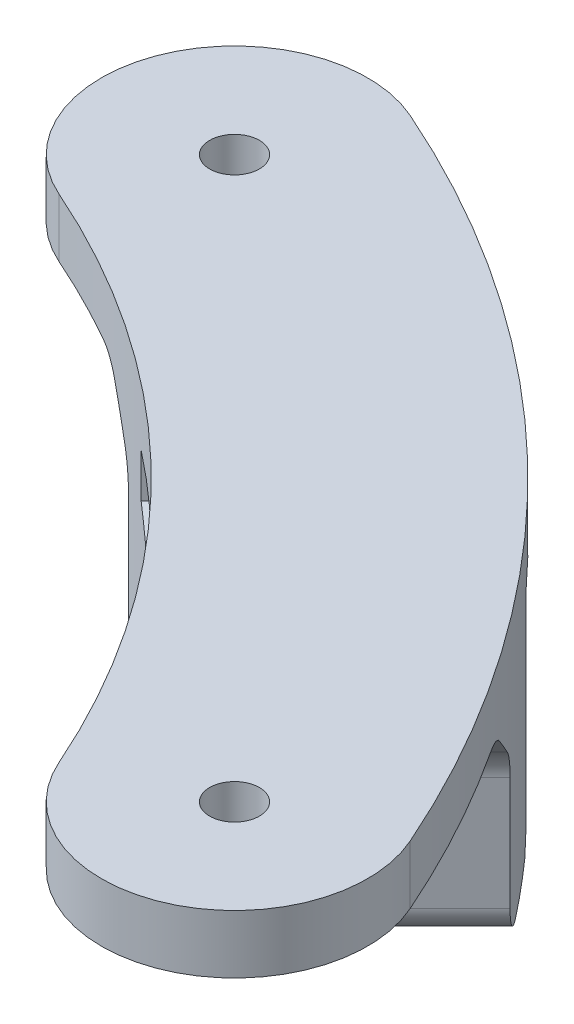
from build123d import *

# Parameters (mm, degrees)
SKETCH1_R           = 1.7
BOSS_EXTRUDE1_DEPTH = 4
SKETCH2_W           = 8
SKETCH2_H           = 15
BOSS_EXTRUDE2_DEPTH = 30
CUT_EXTRUDE1_DEPTH  = 30
SKETCH4_R           = 1.5
CUT_EXTRUDE2_DEPTH  = 52.989471847
FILLET1_R           = 2
CHAMFER1_SIZE       = 1
CHAMFER2_SIZE       = 4
FILLET2_R           = 3


with BuildPart() as part:
    # Sketch1 → Boss-Extrude1 (new body)
    with BuildSketch(Plane.XZ.offset(74.901515315)):
        with BuildLine():
            ThreePointArc((21.566916187, -71.495231174), (26.53319413, -76.858714128), (33.842822155, -76.844426529))
            ThreePointArc((33.842822155, -76.844426529), (59.373405242, -59.373405242), (76.844426529, -33.842822155))
            ThreePointArc((76.844426529, -33.842822155), (76.858714128, -26.53319413), (71.495231174, -21.566916187))
            ThreePointArc((71.495231174, -21.566916187), (64.870172632, -21.821666174), (60.172932274, -26.500579645))
            ThreePointArc((60.172932274, -26.500579645), (46.492270863, -46.492270863), (26.500579645, -60.172932274))
            ThreePointArc((26.500579645, -60.172932274), (21.821666174, -64.870172632), (21.566916187, -71.495231174))
        make_face()
        with Locations((30.1717009, -68.508679402)):
            Circle(SKETCH1_R, mode=Mode.SUBTRACT)
        with Locations((68.508679402, -30.1717009)):
            Circle(SKETCH1_R, mode=Mode.SUBTRACT)
    extrude(amount=BOSS_EXTRUDE1_DEPTH)

    # Sketch2 → Boss-Extrude2 (add)
    with BuildSketch(Plane(origin=(62.280244247, 0, -62.280244247), x_dir=(-0.707106781, 0, -0.707106781), z_dir=(0.707106781, 0, -0.707106781))):
        with Locations((-8, -86.401515315)):
            Rectangle(SKETCH2_W, SKETCH2_H)
        Polygon((4, -93.901515315), (12, -93.901515315), (12, -78.901515315), (8, -78.901515315), (8, -81.901515315), (4, -84.210916392), align=None)
    extrude(amount=-BOSS_EXTRUDE2_DEPTH)

    # Sketch3 → Cut-Extrude1 (cut)
    with BuildSketch(Plane.XZ.offset(93.901515315)):
        with BuildLine():
            Line((29.484052126, -58.768641044), (22.062889108, -51.347478026))
            Line((22.062889108, -51.347478026), (52.677923164, -23.025448826))
            Line((52.677923164, -23.025448826), (58.652501829, -29.714416185))
            ThreePointArc((58.652501829, -29.714416185), (46.400970155, -46.583392627), (29.484052126, -58.768641044))
        make_face()
        with BuildLine():
            Line((72.712363398, -41.991840982), (86.447631041, -52.417601978))
            Line((86.447631041, -52.417601978), (48.404595932, -83.58162252))
            Line((48.404595932, -83.58162252), (40.796709535, -73.389583669))
            ThreePointArc((40.796709535, -73.389583669), (58.885753549, -59.857084201), (72.712363398, -41.991840982))
        make_face()
    extrude(amount=-CUT_EXTRUDE1_DEPTH, mode=Mode.SUBTRACT)

    # Sketch4 → Cut-Extrude2 (cut, through all)
    with BuildSketch(Plane(origin=(8.485281374, 0, 8.485281374), x_dir=(0.707106781, 0, -0.707106781), z_dir=(0.707106781, 0, 0.707106781))):
        with Locations((74.128214207, -88.901515315)):
            Circle(SKETCH4_R)
    extrude(amount=-CUT_EXTRUDE2_DEPTH, mode=Mode.SUBTRACT)

    # Fillet1
    fillet1_edges = [part.edges().sort_by_distance(p)[0] for p in [
        (43.752386609, -93.901515315, -60.722949357),
        (60.722949357, -93.901515315, -43.752386609),
    ]]
    fillet(fillet1_edges, radius=FILLET1_R)

    # Chamfer1
    chamfer1_edges = [part.edges().sort_by_distance(p)[0] for p in [
        (50.0276489, -93.901515315, -55.684503149),
        (55.684503149, -93.901515315, -50.0276489),
    ]]
    chamfer(chamfer1_edges, length=CHAMFER1_SIZE)

    # Chamfer2
    chamfer2_edges = [part.edges().sort_by_distance(p)[0] for p in [
        (60.722949357, -78.901515315, -43.752386609),
        (43.752386609, -78.901515315, -60.722949357),
    ]]
    chamfer(chamfer2_edges, length=CHAMFER2_SIZE)

    # Fillet2
    fillet2_edges = [part.edges().sort_by_distance(p)[0] for p in [
        (63.00381198, -78.901515315, -40.376394982),
        (60.722949357, -82.901515315, -43.752386609),
        (43.752386609, -82.901515315, -60.722949357),
        (40.376394982, -78.901515315, -63.00381198),
    ]]
    fillet(fillet2_edges, radius=FILLET2_R)


solid = part.part
